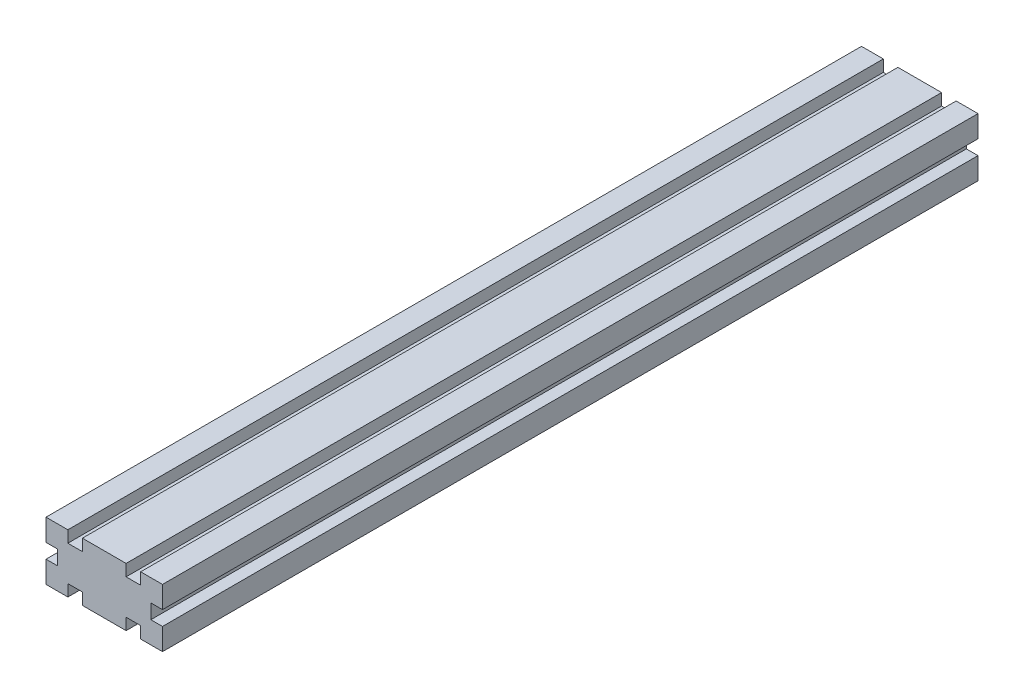
from build123d import *

# Parameters (mm, degrees)
ESQUISSE1_W        = 3.5
ESQUISSE1_H        = 5
ESQUISSE1_W_2      = 5
ESQUISSE1_H_2      = 3.5
ESQUISSE1_W_3      = 4
BOSS_EXTRU_1_DEPTH = 280


with BuildPart() as part:
    # Esquisse1 → Boss.-Extru.1 (new body)
    with BuildSketch(Plane.XY):
        Polygon((7.5, 16), (7.5, 20), (0, 20), (4, 16), align=None)
        Polygon((4, 16), (0, 20), (0, 12.5), (4, 12.5), align=None)
        Polygon((4, 7.5), (0, 7.5), (0, 0), (4, 4), align=None)
        Polygon((0, 0), (7.5, 0), (7.5, 4), (4, 4), align=None)
        Polygon((4, 4), (7.5, 7.5), (4, 7.5), align=None)
        Polygon((7.5, 4), (7.5, 7.5), (4, 4), align=None)
        Polygon((4, 12.5), (7.5, 12.5), (4, 16), align=None)
        Polygon((7.5, 12.5), (7.5, 16), (4, 16), align=None)
        with Locations((5.75, 10)):
            Rectangle(ESQUISSE1_W, ESQUISSE1_H)
        Polygon((7.5, 7.5), (10, 10), (7.5, 12.5), align=None)
        Polygon((10, 10), (12.5, 12.5), (7.5, 12.5), align=None)
        Polygon((12.5, 7.5), (12.5, 12.5), (10, 10), align=None)
        Polygon((12.5, 7.5), (10, 10), (7.5, 7.5), align=None)
        Polygon((16, 4), (12.5, 7.5), (12.5, 4), align=None)
        Polygon((16, 4), (16, 7.5), (12.5, 7.5), align=None)
        Polygon((20, 0), (20, 7.5), (16, 7.5), (16, 4), align=None)
        with Locations((10, 14.25)):
            Rectangle(ESQUISSE1_W_2, ESQUISSE1_H_2)
        with Locations((14.25, 10)):
            Rectangle(ESQUISSE1_W, ESQUISSE1_H)
        Polygon((12.5, 12.5), (16, 16), (12.5, 16), align=None)
        Polygon((16, 16), (20, 20), (12.5, 20), (12.5, 16), align=None)
        Polygon((16, 12.5), (16, 16), (12.5, 12.5), align=None)
        Polygon((20, 12.5), (20, 20), (16, 16), (16, 12.5), align=None)
        Polygon((12.5, 0), (20, 0), (16, 4), (12.5, 4), align=None)
        with Locations((10, 5.75)):
            Rectangle(ESQUISSE1_W_2, ESQUISSE1_H_2)
        with Locations((18, 10)):
            Rectangle(ESQUISSE1_W_3, ESQUISSE1_H)
        with Locations((22, 10)):
            Rectangle(ESQUISSE1_W_3, ESQUISSE1_H)
        Polygon((24, 16), (20, 20), (20, 12.5), (24, 12.5), align=None)
        Polygon((27.5, 20), (20, 20), (24, 16), (27.5, 16), align=None)
        Polygon((27.5, 12.5), (24, 16), (24, 12.5), align=None)
        Polygon((27.5, 16), (24, 16), (27.5, 12.5), align=None)
        with Locations((25.75, 10)):
            Rectangle(ESQUISSE1_W, ESQUISSE1_H)
        Polygon((27.5, 7.5), (24, 7.5), (24, 4), align=None)
        Polygon((24, 7.5), (20, 7.5), (20, 0), (24, 4), align=None)
        Polygon((24, 4), (20, 0), (27.5, 0), (27.5, 4), align=None)
        Polygon((27.5, 4), (27.5, 7.5), (24, 4), align=None)
        with Locations((30, 5.75)):
            Rectangle(ESQUISSE1_W_2, ESQUISSE1_H_2)
        Polygon((36, 4), (32.5, 7.5), (32.5, 4), align=None)
        Polygon((36, 7.5), (32.5, 7.5), (36, 4), align=None)
        Polygon((40, 0), (40, 7.5), (36, 7.5), (36, 4), align=None)
        Polygon((32.5, 4), (32.5, 0), (40, 0), (36, 4), align=None)
        with Locations((34.25, 10)):
            Rectangle(ESQUISSE1_W, ESQUISSE1_H)
        Polygon((32.5, 12.5), (30, 10), (32.5, 7.5), align=None)
        Polygon((32.5, 7.5), (30, 10), (27.5, 7.5), align=None)
        Polygon((30, 10), (27.5, 12.5), (27.5, 7.5), align=None)
        Polygon((32.5, 12.5), (27.5, 12.5), (30, 10), align=None)
        Polygon((36, 16), (32.5, 12.5), (36, 12.5), align=None)
        Polygon((36, 16), (32.5, 16), (32.5, 12.5), align=None)
        Polygon((40, 20), (32.5, 20), (32.5, 16), (36, 16), align=None)
        Polygon((40, 12.5), (40, 20), (36, 16), (36, 12.5), align=None)
        with Locations((30, 14.25)):
            Rectangle(ESQUISSE1_W_2, ESQUISSE1_H_2)
    extrude(amount=BOSS_EXTRU_1_DEPTH)


solid = part.part
